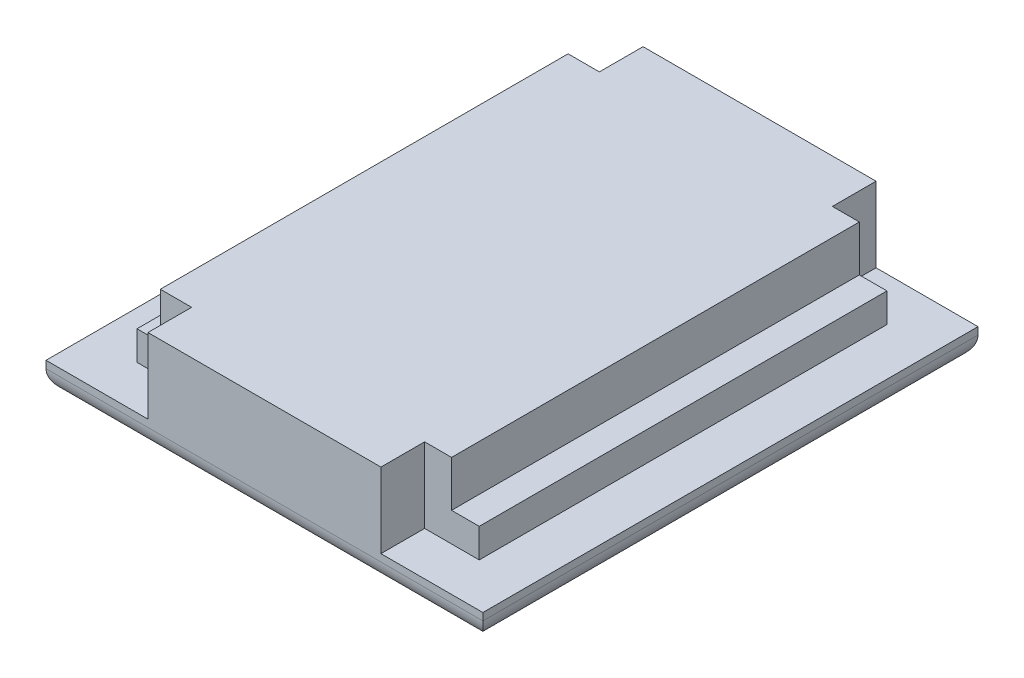
from build123d import *

# Parameters (mm, degrees)
SKETCH1_W           = 38.1
SKETCH1_H           = 43.18
BOSS_EXTRUDE1_DEPTH = 2.54
SKETCH2_W           = 29.845
SKETCH2_H           = 35.56
BOSS_EXTRUDE2_DEPTH = 2.54
SKETCH3_W           = 25.4
SKETCH3_H           = 35.56
BOSS_EXTRUDE3_DEPTH = 4
SKETCH7_W           = 20.32
SKETCH7_H           = 3.81
BOSS_EXTRUDE5_DEPTH = 6.54
FILLET1_R           = 1.905


with BuildPart() as part:
    # Sketch1 → Boss-Extrude1 (new body)
    with BuildSketch(Plane(origin=(0, 0, 0), x_dir=(1, 0, 0), z_dir=(0, 1, 0))):
        with Locations((-0.216477273, -10.297102273)):
            Rectangle(SKETCH1_W, SKETCH1_H)
    extrude(amount=BOSS_EXTRUDE1_DEPTH)

    # Sketch2 → Boss-Extrude2 (add)
    with BuildSketch(Plane(origin=(0, 2.54, 0), x_dir=(1, 0, 0), z_dir=(0, 1, 0))):
        with Locations((-0.216477273, -10.297102273)):
            Rectangle(SKETCH2_W, SKETCH2_H)
    extrude(amount=BOSS_EXTRUDE2_DEPTH)

    # Sketch3 → Boss-Extrude3 (add)
    with BuildSketch(Plane(origin=(0, 5.08, 0), x_dir=(1, 0, 0), z_dir=(0, 1, 0))):
        with Locations((-0.406977273, -10.297102273)):
            Rectangle(SKETCH3_W, SKETCH3_H)
    extrude(amount=BOSS_EXTRUDE3_DEPTH)

    # Sketch7 → Boss-Extrude5 (add)
    with BuildSketch(Plane(origin=(0, 2.54, 0), x_dir=(1, 0, 0), z_dir=(0, 1, 0))):
        with Locations((-0.216477273, -29.982102273)):
            Rectangle(SKETCH7_W, SKETCH7_H)
        with Locations((-0.216477273, 9.387897727)):
            Rectangle(SKETCH7_W, SKETCH7_H)
    extrude(amount=BOSS_EXTRUDE5_DEPTH)

    # Fillet1
    fillet1_edges = [part.edges().sort_by_distance(p)[0] for p in [
        (-0.216477273, 0, -11.292897727),
        (18.833522727, 0, 10.297102273),
        (-0.216477273, 0, 31.887102273),
        (-19.266477273, 0, 10.297102273),
    ]]
    fillet(fillet1_edges, radius=FILLET1_R)


solid = part.part
